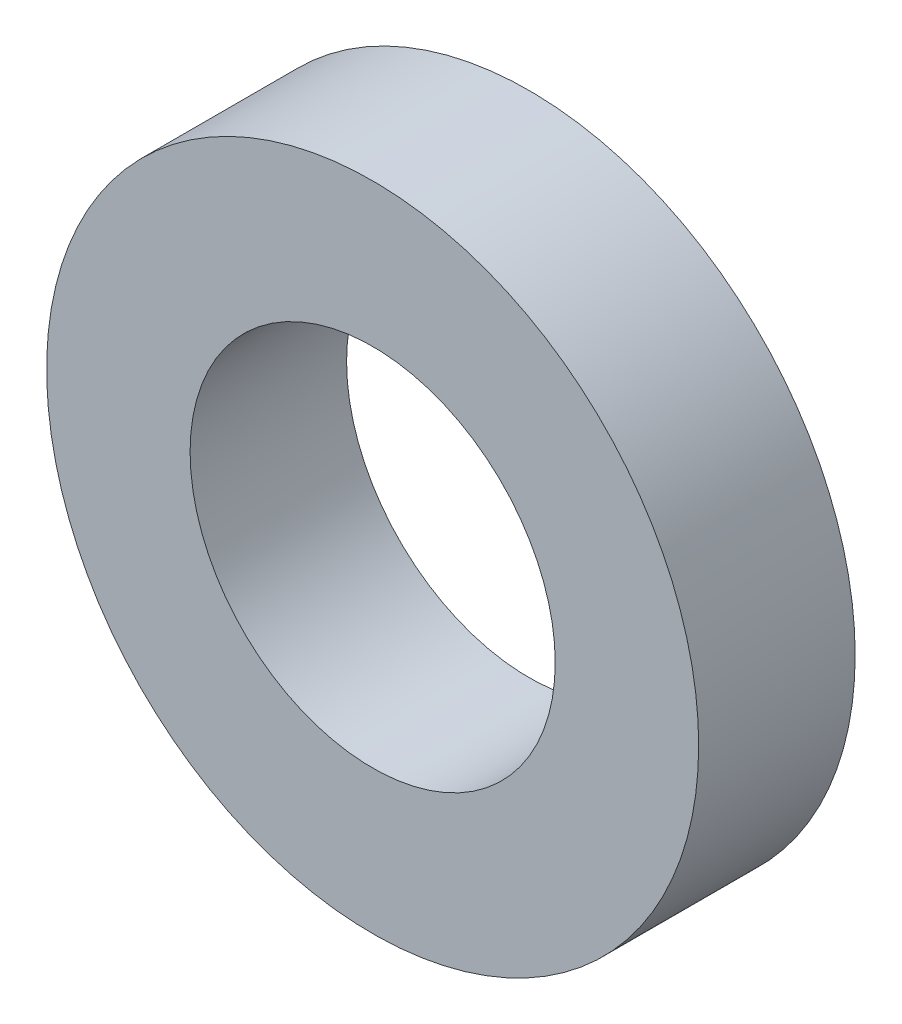
from build123d import *

# Parameters (mm, degrees)
SKETCH1_R           = 12.5
SKETCH1_R_2         = 7
BOSS_EXTRUDE1_DEPTH = 6


with BuildPart() as part:
    # Sketch1 → Boss-Extrude1 (new body)
    with BuildSketch(Plane.XY):
        Circle(SKETCH1_R)
        Circle(SKETCH1_R_2, mode=Mode.SUBTRACT)
    extrude(amount=BOSS_EXTRUDE1_DEPTH)


solid = part.part
